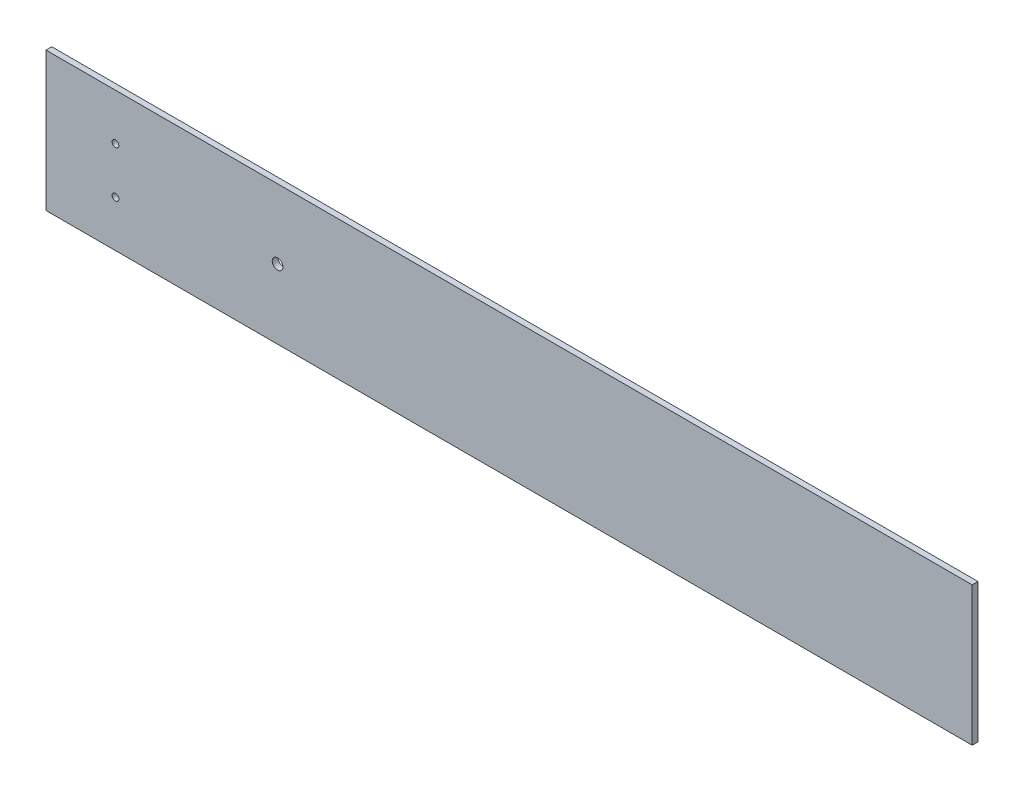
from build123d import *

# Parameters (mm, degrees)
SKETCH1_W            = 508
SKETCH1_H            = 76.2
BASIC_PLANK_DEPTH    = 3.175
SKETCH3_R            = 1.8415
CUT_EXTRUDE4_DEPTH   = 4.175
SKETCH4_R            = 2.921
THROUGH_TRIPOD_DEPTH = 4.175


with BuildPart() as part:
    # Sketch1 → basic_plank (new body)
    with BuildSketch(Plane.XY):
        with Locations((254, 38.1)):
            Rectangle(SKETCH1_W, SKETCH1_H)
    extrude(amount=BASIC_PLANK_DEPTH)

    # Sketch3 → Cut-Extrude4 (cut, through all)
    with BuildSketch(Plane.XY.offset(3.175)):
        with Locations((38.1, 50.8)):
            Circle(SKETCH3_R)
        with Locations((38.1, 25.4)):
            Circle(SKETCH3_R)
    extrude(amount=-CUT_EXTRUDE4_DEPTH, mode=Mode.SUBTRACT)

    # Sketch4 → through_tripod (cut, through all)
    with BuildSketch(Plane.XY.offset(3.175)):
        with Locations((127, 38.1)):
            Circle(SKETCH4_R)
    extrude(amount=-THROUGH_TRIPOD_DEPTH, mode=Mode.SUBTRACT)


solid = part.part
